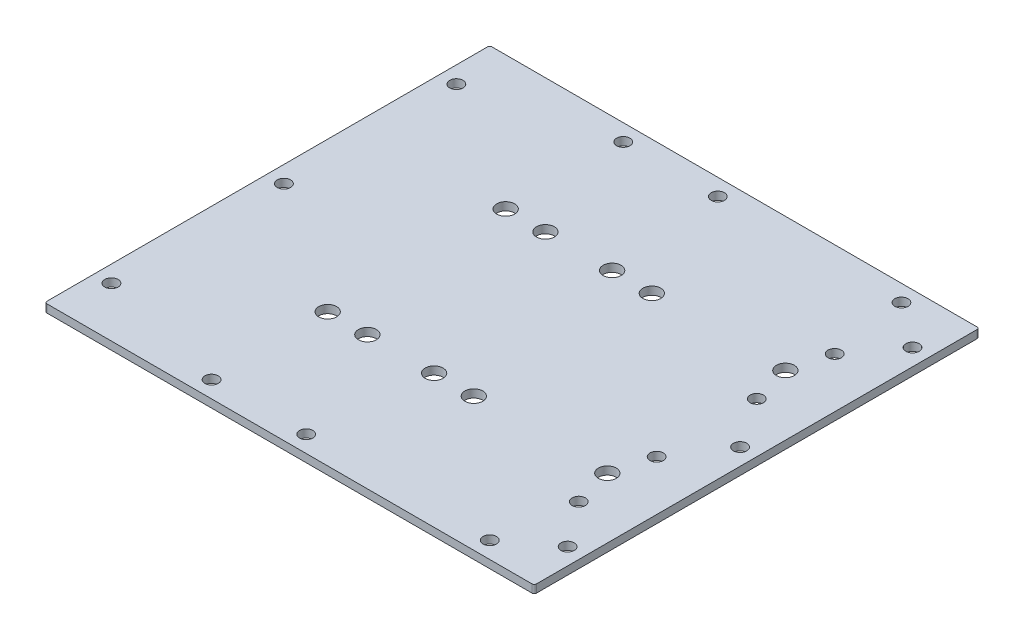
from build123d import *

# Parameters (mm, degrees)
SKETCH1_W           = 139.7
SKETCH1_H           = 127
SKETCH1_R           = 2.5527
BOSS_EXTRUDE1_DEPTH = 2.286
SKETCH2_R           = 1.89865
CUT_EXTRUDE1_DEPTH  = 3.286
FILLET1_R           = 0.635
SKETCH4_R           = 1.89865
CUT_EXTRUDE3_DEPTH  = 3.286


with BuildPart() as part:
    # Sketch1 → Boss-Extrude1 (new body)
    with BuildSketch(Plane(origin=(0, 0, 0), x_dir=(1, 0, 0), z_dir=(0, 1, 0))):
        Rectangle(SKETCH1_W, SKETCH1_H)
        with Locations((-15.875, 25.4)):
            Circle(SKETCH1_R, mode=Mode.SUBTRACT)
        with Locations((3.175, 25.4)):
            Circle(SKETCH1_R, mode=Mode.SUBTRACT)
        with Locations((-15.875, -25.4)):
            Circle(SKETCH1_R, mode=Mode.SUBTRACT)
        with Locations((3.175, -25.4)):
            Circle(SKETCH1_R, mode=Mode.SUBTRACT)
        with Locations((-27.2034, 25.4)):
            Circle(SKETCH1_R, mode=Mode.SUBTRACT)
        with Locations((14.5034, 25.4)):
            Circle(SKETCH1_R, mode=Mode.SUBTRACT)
        with Locations((14.5034, -25.4)):
            Circle(SKETCH1_R, mode=Mode.SUBTRACT)
        with Locations((-27.2034, -25.4)):
            Circle(SKETCH1_R, mode=Mode.SUBTRACT)
        with Locations((52.6034, 25.4)):
            Circle(SKETCH1_R, mode=Mode.SUBTRACT)
        with Locations((52.6034, -25.4)):
            Circle(SKETCH1_R, mode=Mode.SUBTRACT)
    extrude(amount=BOSS_EXTRUDE1_DEPTH)

    # Sketch2 → Cut-Extrude1 (cut, through all)
    with BuildSketch(Plane.XZ):
        with Locations((0, 58.7375)):
            Circle(SKETCH2_R)
        with Locations((-65.0875, 49.2125)):
            Circle(SKETCH2_R)
        with Locations((65.0875, 49.2125)):
            Circle(SKETCH2_R)
        with Locations((-65.0875, 0)):
            Circle(SKETCH2_R)
        with Locations((65.0875, 0)):
            Circle(SKETCH2_R)
        with Locations((52.3875, 58.7375)):
            Circle(SKETCH2_R)
        with Locations((-26.9875, 58.7375)):
            Circle(SKETCH2_R)
        with Locations((-26.9875, -58.7375)):
            Circle(SKETCH2_R)
        with Locations((52.3875, -58.7375)):
            Circle(SKETCH2_R)
        with Locations((65.0875, -49.2125)):
            Circle(SKETCH2_R)
        with Locations((-65.0875, -49.2125)):
            Circle(SKETCH2_R)
        with Locations((0, -58.7375)):
            Circle(SKETCH2_R)
    extrude(amount=-CUT_EXTRUDE1_DEPTH, mode=Mode.SUBTRACT)

    # Fillet1
    fillet1_edges = [part.edges().sort_by_distance(p)[0] for p in [
        (69.85, 1.143, 63.5),
        (-69.85, 1.143, 63.5),
        (-69.85, 1.143, -63.5),
        (69.85, 1.143, -63.5),
    ]]
    fillet(fillet1_edges, radius=FILLET1_R)

    # Sketch4 → Cut-Extrude3 (cut, through all)
    with BuildSketch(Plane.XZ):
        with Locations((55.5625, 36.5125)):
            Circle(SKETCH4_R)
        with Locations((55.5625, 14.2875)):
            Circle(SKETCH4_R)
        with Locations((55.5625, -14.2875)):
            Circle(SKETCH4_R)
        with Locations((55.5625, -36.5125)):
            Circle(SKETCH4_R)
    extrude(amount=-CUT_EXTRUDE3_DEPTH, mode=Mode.SUBTRACT)


solid = part.part
